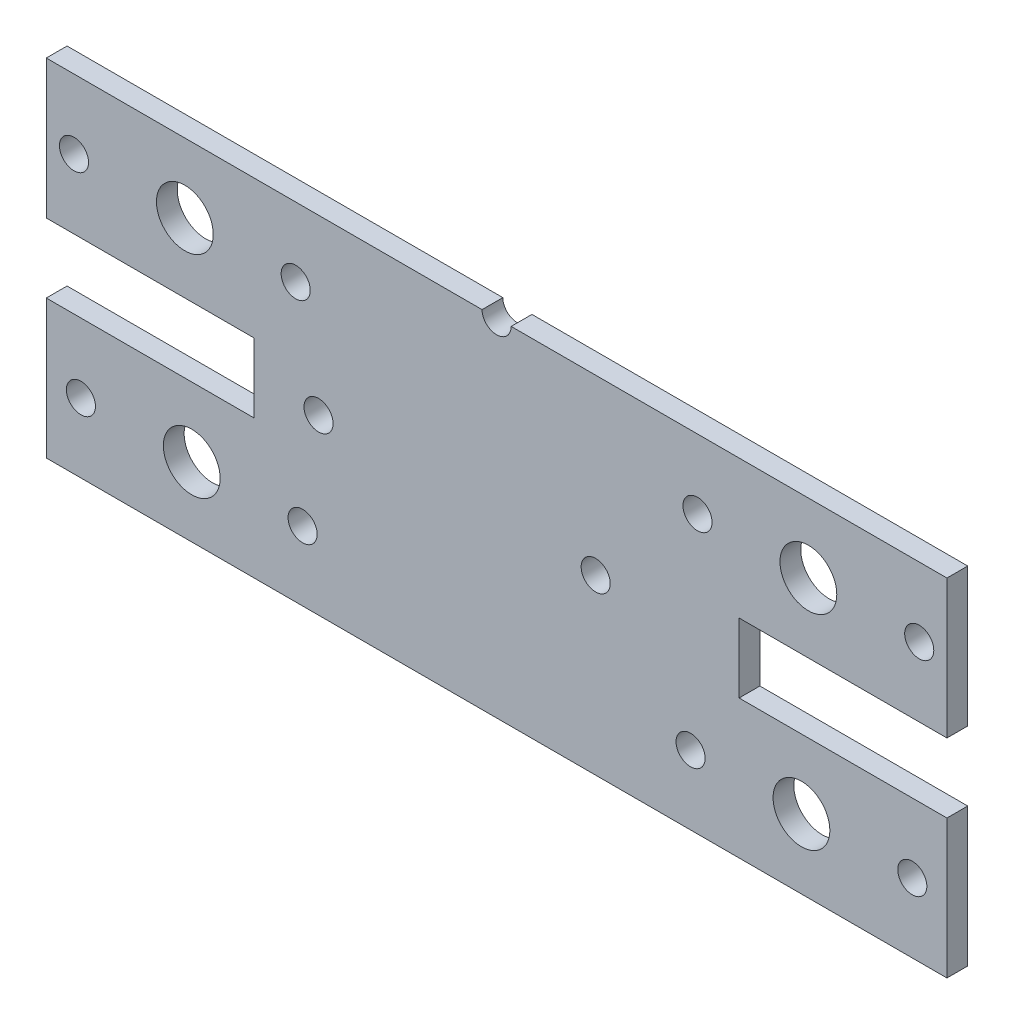
from build123d import *

# Parameters (mm, degrees)
ESQUISSE1_W             = 130
ESQUISSE1_H             = 50
ESQUISSE1_R             = 2.1
ESQUISSE1_R_2           = 4.1
BOSS_EXTRU_1_DEPTH      = 3
ENL_V_MAT_EXTRU_1_REACH = 5
ESQUISSE2_W             = 30
ESQUISSE2_H             = 10


with BuildPart() as part:
    # Esquisse1 → Boss.-Extru.1 (new body)
    with BuildSketch(Plane.XY):
        with Locations((65, 25)):
            Rectangle(ESQUISSE1_W, ESQUISSE1_H)
        with Locations((4, 40)):
            Circle(ESQUISSE1_R, mode=Mode.SUBTRACT)
        with Locations((20, 40)):
            Circle(ESQUISSE1_R_2, mode=Mode.SUBTRACT)
        with Locations((36, 40)):
            Circle(ESQUISSE1_R, mode=Mode.SUBTRACT)
        with Locations((94, 40)):
            Circle(ESQUISSE1_R, mode=Mode.SUBTRACT)
        with Locations((110, 40)):
            Circle(ESQUISSE1_R_2, mode=Mode.SUBTRACT)
        with Locations((126, 40)):
            Circle(ESQUISSE1_R, mode=Mode.SUBTRACT)
        with Locations((5, 10)):
            Circle(ESQUISSE1_R, mode=Mode.SUBTRACT)
        with Locations((21, 10)):
            Circle(ESQUISSE1_R_2, mode=Mode.SUBTRACT)
        with Locations((37, 10)):
            Circle(ESQUISSE1_R, mode=Mode.SUBTRACT)
        with Locations((93, 10)):
            Circle(ESQUISSE1_R, mode=Mode.SUBTRACT)
        with Locations((109, 10)):
            Circle(ESQUISSE1_R_2, mode=Mode.SUBTRACT)
        with Locations((125, 10)):
            Circle(ESQUISSE1_R, mode=Mode.SUBTRACT)
        with Locations((39.3, 25)):
            Circle(ESQUISSE1_R, mode=Mode.SUBTRACT)
        with Locations((79.3, 25)):
            Circle(ESQUISSE1_R, mode=Mode.SUBTRACT)
    extrude(amount=BOSS_EXTRU_1_DEPTH)

    # Esquisse2 → Enlèv. mat.-Extru.1 (cut, up to next)
    with BuildSketch(Plane(origin=(0, 0, 0), x_dir=(-1, 0, 0), z_dir=(0, 0, -1)), mode=Mode.PRIVATE) as enl_v_mat_extru_1_sk1:
        with Locations((-15, 25)):
            Rectangle(ESQUISSE2_W, ESQUISSE2_H)
    enl_v_mat_extru_1_tool1 = extrude(enl_v_mat_extru_1_sk1.sketch, amount=-ENL_V_MAT_EXTRU_1_REACH, mode=Mode.PRIVATE) & part.part
    add(enl_v_mat_extru_1_tool1.solids().sort_by_distance((15, 25, 0))[0], mode=Mode.SUBTRACT)
    # Esquisse2 → Enlèv. mat.-Extru.1 (cut, up to next)
    with BuildSketch(Plane(origin=(0, 0, 0), x_dir=(-1, 0, 0), z_dir=(0, 0, -1)), mode=Mode.PRIVATE) as enl_v_mat_extru_1_sk2:
        with Locations((-115, 25)):
            Rectangle(ESQUISSE2_W, ESQUISSE2_H)
    enl_v_mat_extru_1_tool2 = extrude(enl_v_mat_extru_1_sk2.sketch, amount=-ENL_V_MAT_EXTRU_1_REACH, mode=Mode.PRIVATE) & part.part
    add(enl_v_mat_extru_1_tool2.solids().sort_by_distance((115, 25, 0))[0], mode=Mode.SUBTRACT)
    # Esquisse2 → Enlèv. mat.-Extru.1 (cut, up to next)
    with BuildSketch(Plane(origin=(0, 0, 0), x_dir=(-1, 0, 0), z_dir=(0, 0, -1)), mode=Mode.PRIVATE) as enl_v_mat_extru_1_sk3:
        with BuildLine():
            Line((-62.9, 50), (-67.1, 50))
            ThreePointArc((-67.1, 50), (-65, 47.9), (-62.9, 50))
        make_face()
    enl_v_mat_extru_1_tool3 = extrude(enl_v_mat_extru_1_sk3.sketch, amount=-ENL_V_MAT_EXTRU_1_REACH, mode=Mode.PRIVATE) & part.part
    add(enl_v_mat_extru_1_tool3.solids().sort_by_distance((65, 49.108732, 0))[0], mode=Mode.SUBTRACT)


solid = part.part
